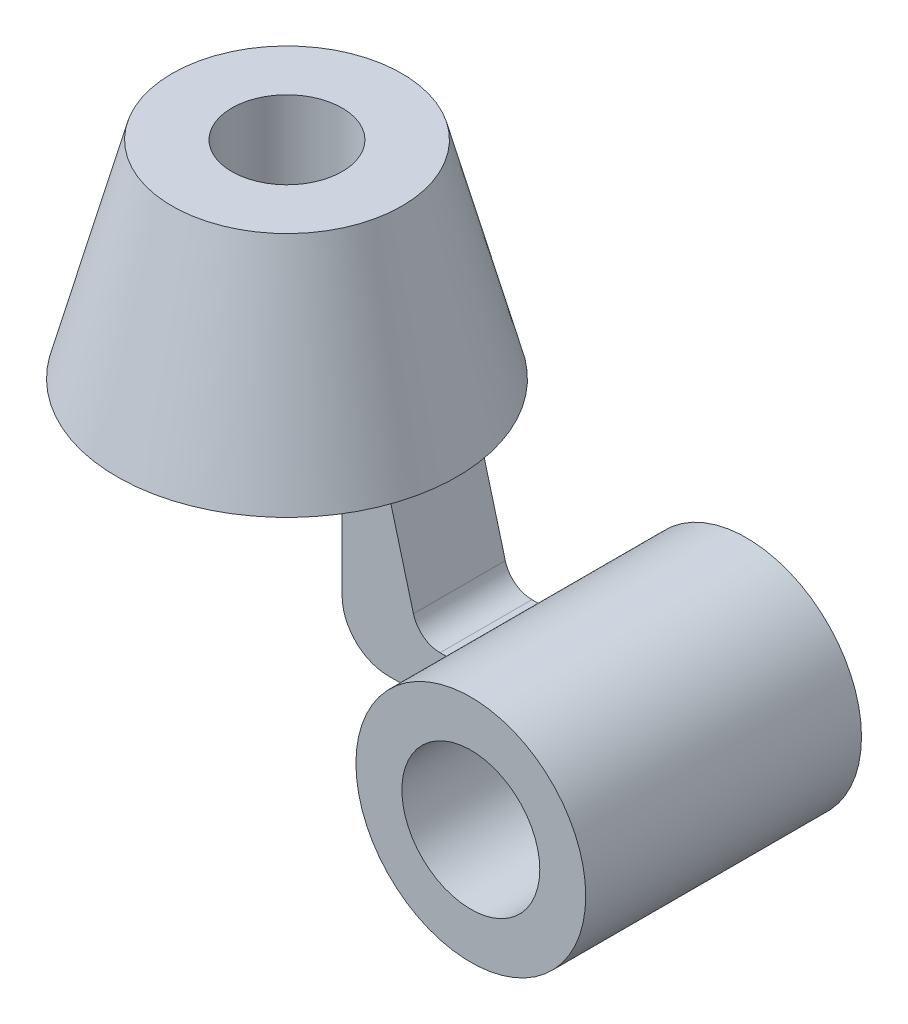
from build123d import *

# Parameters (mm, degrees)
SKETCH2_R           = 12
CUT_EXTRUDE1_DEPTH  = 45
BOSS_EXTRUDE1_DEPTH = 10
SKETCH4_R           = 25
SKETCH4_R_2         = 15
BOSS_EXTRUDE2_DEPTH = 30


with BuildPart() as part:
    # Sketch1 → Revolve1 (revolve)
    with BuildSketch(Plane.XY):
        Polygon((0, 45), (0, 0), (37, 0), (25, 45), align=None)
    revolve(axis=Axis((0, 45, 0), (0, -1, 0)))

    # Sketch2 → Cut-Extrude1 (cut)
    with BuildSketch(Plane(origin=(0, 45, 0), x_dir=(1, 0, 0), z_dir=(0, 1, 0))):
        Circle(SKETCH2_R)
    extrude(amount=-CUT_EXTRUDE1_DEPTH, mode=Mode.SUBTRACT)

    # Sketch3 → Boss-Extrude1 (add, symmetric)
    with BuildSketch(Plane.XY):
        with BuildLine():
            Line((22, 0), (32, 0))
            Line((32, 0), (37.507136781, -20.552914271))
            ThreePointArc((37.507136781, -20.552914271), (39.650123165, -23.760120042), (43.302691739, -25))
            Line((43.302691739, -25), (50.574709256, -25))
            Line((50.574709256, -25), (50.574709256, -35))
            Line((50.574709256, -35), (32, -35))
            ThreePointArc((32, -35), (24.928932188, -32.071067812), (22, -25))
            Line((22, -25), (22, 0))
        make_face()
    extrude(amount=BOSS_EXTRUDE1_DEPTH, both=True)

    # Sketch4 → Boss-Extrude2 (add, symmetric)
    with BuildSketch(Plane.XY):
        with Locations((70, -35)):
            Circle(SKETCH4_R)
        with Locations((70, -35)):
            Circle(SKETCH4_R_2, mode=Mode.SUBTRACT)
    extrude(amount=BOSS_EXTRUDE2_DEPTH, both=True)


solid = part.part
